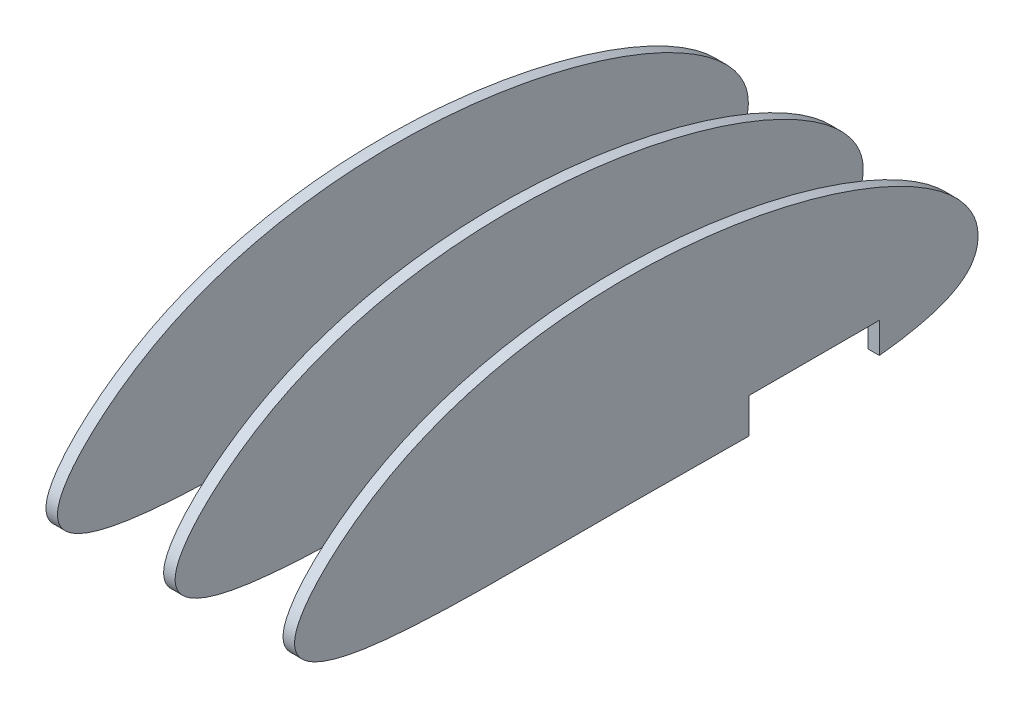
from build123d import *

# Parameters (mm, degrees)
AUFSATZ_LINEAR_AUSTRAGEN1_DEPTH = 5
AUFSATZ_LINEAR_AUSTRAGEN2_DEPTH = 5
AUFSATZ_LINEAR_AUSTRAGEN3_DEPTH = 5
SKIZZE6_W                       = 56.778057412
SKIZZE6_H                       = 23.09155445
SCHNITT_LINEAR_AUSTRAGEN2_DEPTH = 342.437715458


with BuildPart() as part:
    # Skizze3 → Aufsatz-Linear austragen1 (new body)
    with BuildSketch(Plane(origin=(50, 0, 0), x_dir=(0, 0, -1), z_dir=(1, 0, 0))):
        with BuildLine():
            add(Edge.make_bspline(
                [(-26.833255807, 32.258899596), (-29.851358797, 34.013625224), (-32.926865489, 35.630950416), (-39.164492471, 38.658284107), (-42.326908849, 40.067583895), (-48.722868649, 42.715935101), (-51.956534754, 43.954692869), (-58.48535321, 46.285036067), (-61.780563865, 47.376481945), (-66.764858936, 48.914367189), (-68.432672738, 49.410189153), (-71.77061665, 50.367007077), (-73.442119314, 50.828430966), (-78.463863987, 52.164133017), (-81.821324876, 52.989961027), (-91.92052948, 55.287427261), (-98.688922508, 56.580206268), (-112.291510392, 58.724129508), (-119.12576448, 59.5748762), (-132.859878253, 60.836051827), (-139.759745786, 61.246428093), (-150.161636826, 61.512387606), (-153.64146646, 61.542367078), (-160.576267019, 61.480505172), (-164.035748875, 61.388909929), (-174.389655741, 60.926129311), (-181.259661858, 60.367866929), (-194.927558547, 58.698853575), (-201.725542922, 57.588821232), (-211.859918134, 55.444173868), (-215.227559079, 54.648970866), (-220.261824369, 53.324424106), (-221.937044055, 52.860930623), (-225.281446325, 51.887692457), (-226.950348053, 51.377923863), (-235.232635317, 48.722323863), (-241.696023638, 46.246665465), (-251.112452733, 41.930763735), (-254.204325096, 40.390657114), (-260.284423309, 37.086372938), (-263.273472787, 35.323975967), (-267.678810808, 32.511243533), (-269.135957919, 31.544003616), (-272.011206933, 29.56007375), (-273.429877513, 28.543151982), (-276.228071979, 26.457763579), (-277.60763413, 25.389347329), (-280.324585393, 23.196985146), (-281.663119012, 22.072061011), (-284.287332877, 19.764499945), (-285.571587926, 18.583290757), (-288.075512369, 16.157268145), (-289.29533925, 14.912609817), (-291.065128113, 12.986581868), (-291.645001532, 12.33466916), (-292.781516557, 11.007964954), (-293.338839283, 10.332341733), (-294.964339533, 8.271186008), (-295.985872753, 6.855250252), (-297.37646587, 4.63594147), (-297.816125377, 3.87999717), (-298.631211972, 2.325277135), (-299.002733323, 1.534273861), (-299.647519027, -0.084947376), (-299.920544218, -0.913255921), (-300.224344916, -2.195766498), (-300.307525042, -2.629519756), (-300.429572383, -3.495880552), (-300.468930012, -3.930346053), (-300.498780863, -4.802175406), (-300.489285502, -5.239538581), (-300.414688359, -6.117563179), (-300.349464161, -6.554458099), (-300.072105521, -7.831762299), (-299.777515648, -8.649484794), (-299.172305365, -9.825718231), (-298.945748367, -10.20435367), (-298.453903828, -10.928443234), (-298.187783852, -11.275521559), (-297.619751922, -11.943156429), (-297.316351221, -12.265070398), (-296.686184308, -12.877143822), (-296.359636004, -13.16747451), (-295.351228508, -13.999063885), (-294.640880886, -14.501295454), (-293.164233593, -15.429108271), (-292.394168575, -15.856136567), (-290.053588188, -17.031389482), (-288.449835707, -17.680938488), (-285.191929248, -18.824350074), (-283.53711849, -19.316183908), (-280.193013526, -20.193334806), (-278.503520075, -20.578036414), (-275.099379243, -21.269741038), (-273.391984444, -21.575034593), (-269.976417288, -22.12454518), (-268.266860954, -22.368887635), (-263.134107502, -23.031843465), (-259.706888345, -23.381456015), (-252.845585371, -23.962913198), (-249.411456229, -24.193980233), (-242.538456971, -24.574779678), (-239.099568812, -24.724202538), (-228.777863429, -25.085990931), (-221.890104005, -25.213569656), (-208.108197071, -25.359135118), (-201.213530991, -25.375719573), (-187.424844878, -25.370801936), (-180.530447593, -25.34851284), (-166.741706347, -25.323434192), (-159.847364382, -25.321374591), (-139.164627733, -25.420967207), (-125.376142872, -25.610238241), (-104.694368878, -25.767623319), (-97.800721054, -25.798501526), (-84.014949045, -25.741469453), (-77.122808403, -25.654842286), (-66.786890118, -25.3461561), (-63.341971704, -25.213035699), (-56.453228064, -24.861566041), (-53.006260011, -24.64319065), (-46.132179133, -24.085770314), (-42.705531983, -23.747354802), (-35.883105401, -22.893200903), (-32.487086531, -22.378838002), (-27.429710278, -21.396742057), (-25.750104104, -21.03384113), (-22.407331125, -20.21360158), (-20.744109912, -19.756575513), (-18.266433369, -18.97248611), (-17.443423197, -18.694566969), (-15.804409746, -18.098476858), (-14.990014665, -17.780789742), (-12.583150783, -16.763832303), (-11.019945661, -16.000372602), (-8.770022399, -14.659115134), (-8.036400343, -14.178684584), (-6.634008753, -13.15236791), (-5.962401343, -12.604817087), (-4.69186901, -11.425231905), (-4.091700298, -10.792276622), (-2.985764252, -9.426364713), (-2.493720363, -8.708742893), (-1.64178977, -7.198301742), (-1.280349229, -6.40563295), (-0.688494026, -4.74870608), (-0.465470822, -3.906480078), (-0.148551378, -2.197652061), (-0.054259608, -1.331124712), (0.009015269, 0.425585196), (-0.023272577, 1.296547322), (-0.204882199, 3.024886421), (-0.354253647, 3.882266541), (-0.660678375, 5.15878813), (-0.776748792, 5.582960311), (-1.031925719, 6.417598837), (-1.171333474, 6.829476102), (-1.922778957, 8.863811761), (-2.696066415, 10.412025382), (-4.050533485, 12.644774982), (-4.535917718, 13.37499786), (-5.548774775, 14.787303971), (-6.077959959, 15.472443023), (-7.723437355, 17.474373853), (-8.897127639, 18.73816297), (-11.361182445, 21.158001606), (-12.652410629, 22.314216799), (-15.327113818, 24.53753381), (-16.700770872, 25.596492069), (-19.506293713, 27.629914005), (-20.938241057, 28.604259295), (-23.122695916, 30.012745467), (-23.8569658, 30.473359714), (-24.966856155, 31.151963666), (-25.338235095, 31.376110291), (-26.083722091, 31.82044201), (-26.455992934, 32.039558893), (-26.833255807, 32.258899596)],
                knots=[0, 0, 0, 0, 0.015625, 0.015625, 0.03125, 0.03125, 0.046875, 0.046875, 0.0625, 0.0625, 0.0703125, 0.0703125, 0.078125, 0.078125, 0.09375, 0.09375, 0.125, 0.125, 0.15625, 0.15625, 0.1875, 0.1875, 0.203125, 0.203125, 0.21875, 0.21875, 0.25, 0.25, 0.28125, 0.28125, 0.296875, 0.296875, 0.3046875, 0.3046875, 0.3125, 0.3125, 0.34375, 0.34375, 0.359375, 0.359375, 0.375, 0.375, 0.3828125, 0.3828125, 0.390625, 0.390625, 0.3984375, 0.3984375, 0.40625, 0.40625, 0.4140625, 0.4140625, 0.421875, 0.421875, 0.42578125, 0.42578125, 0.4296875, 0.4296875, 0.4375, 0.4375, 0.44140625, 0.44140625, 0.4453125, 0.4453125, 0.44921875, 0.44921875, 0.451171875, 0.451171875, 0.453125, 0.453125, 0.455078125, 0.455078125, 0.45703125, 0.45703125, 0.4609375, 0.4609375, 0.462890625, 0.462890625, 0.46484375, 0.46484375, 0.466796875, 0.466796875, 0.46875, 0.46875, 0.47265625, 0.47265625, 0.4765625, 0.4765625, 0.484375, 0.484375, 0.4921875, 0.4921875, 0.5, 0.5, 0.5078125, 0.5078125, 0.515625, 0.515625, 0.53125, 0.53125, 0.546875, 0.546875, 0.5625, 0.5625, 0.59375, 0.59375, 0.625, 0.625, 0.65625, 0.65625, 0.6875, 0.6875, 0.75, 0.75, 0.78125, 0.78125, 0.8125, 0.8125, 0.828125, 0.828125, 0.84375, 0.84375, 0.859375, 0.859375, 0.875, 0.875, 0.8828125, 0.8828125, 0.890625, 0.890625, 0.89453125, 0.89453125, 0.8984375, 0.8984375, 0.90625, 0.90625, 0.91015625, 0.91015625, 0.9140625, 0.9140625, 0.91796875, 0.91796875, 0.921875, 0.921875, 0.92578125, 0.92578125, 0.9296875, 0.9296875, 0.93359375, 0.93359375, 0.9375, 0.9375, 0.94140625, 0.94140625, 0.943359375, 0.943359375, 0.9453125, 0.9453125, 0.953125, 0.953125, 0.95703125, 0.95703125, 0.9609375, 0.9609375, 0.96875, 0.96875, 0.9765625, 0.9765625, 0.984375, 0.984375, 0.9921875, 0.9921875, 0.99609375, 0.99609375, 0.998046875, 0.998046875, 1, 1, 1, 1], degree=3))
        make_face()
    extrude(amount=-AUFSATZ_LINEAR_AUSTRAGEN1_DEPTH)


with BuildPart() as body_2:
    # Skizze4 → Aufsatz-Linear austragen2 (new body)
    with BuildSketch(Plane(origin=(100, 0, 0), x_dir=(0, 0, -1), z_dir=(1, 0, 0))):
        with BuildLine():
            add(Edge.make_bspline(
                [(-26.87177587, 32.151781888), (-29.878894348, 33.89463758), (-32.942730126, 35.501247503), (-39.156051981, 38.508718999), (-42.305828882, 39.908881957), (-48.675754179, 42.540162128), (-51.896023277, 43.770989389), (-58.397416699, 46.086458059), (-61.67859844, 47.170961539), (-66.641435263, 48.699072691), (-68.302338847, 49.191837828), (-71.626330072, 50.142732482), (-73.290816173, 50.601298799), (-78.291396881, 51.928720699), (-81.634596414, 52.749417716), (-91.690597857, 55.03254517), (-98.429632987, 56.31716174), (-111.972490564, 58.447253877), (-118.77637117, 59.292335225), (-132.448729883, 60.544643511), (-139.317215638, 60.951818608), (-149.671231272, 61.214948011), (-153.135782077, 61.244336604), (-160.041617155, 61.181863301), (-163.486559206, 61.090252697), (-173.796670884, 60.628333839), (-180.637246552, 60.071850847), (-194.24577759, 58.409153681), (-201.013825363, 57.303639007), (-211.102874823, 55.16829284), (-214.455336673, 54.376612838), (-219.466717773, 53.058044531), (-221.13428997, 52.596658493), (-224.463358185, 51.627890122), (-226.125194484, 51.120300624), (-234.372356883, 48.476122229), (-240.80803442, 46.011438609), (-250.183810764, 41.71568129), (-253.262311222, 40.182963943), (-259.31590015, 36.894601103), (-262.291748987, 35.140594751), (-266.677332836, 32.341030112), (-268.127925198, 31.378251095), (-270.990680253, 29.402918386), (-272.403114934, 28.390337405), (-275.188852279, 26.313706961), (-276.562193583, 25.249708319), (-279.266721702, 23.066267238), (-280.599069102, 21.945827451), (-283.210775593, 19.647440911), (-284.488821234, 18.470827665), (-286.980401076, 16.053989004), (-288.194093807, 14.813919908), (-289.954728193, 12.894746605), (-290.531557956, 12.245113876), (-291.661996785, 10.922951411), (-292.216339051, 10.249512877), (-293.83188939, 8.196221492), (-294.846829908, 6.785585914), (-296.227597938, 4.574338828), (-296.6639532, 3.821176637), (-297.472610357, 2.271758741), (-297.841152885, 1.482958642), (-298.479692253, -0.131243641), (-298.749591731, -0.956973246), (-299.048525837, -2.23553175), (-299.129881155, -2.667047922), (-299.248549161, -3.529411654), (-299.286283459, -3.961919451), (-299.313003734, -4.829927533), (-299.302001326, -5.265427106), (-299.224477293, -6.139834383), (-299.158019922, -6.57377524), (-298.877473992, -7.843616055), (-298.581482855, -8.656592992), (-297.975260569, -9.82605445), (-297.748791564, -10.2021202), (-297.257345018, -10.921650901), (-296.991617113, -11.266561251), (-296.424710408, -11.930056895), (-296.122050106, -12.249984206), (-295.493790505, -12.858182868), (-295.168316823, -13.146714227), (-294.163424111, -13.973234724), (-293.455803913, -14.472521502), (-291.985138165, -15.395031118), (-291.2183536, -15.819694115), (-288.887739609, -16.988715971), (-287.291053651, -17.635065734), (-284.047719516, -18.77302907), (-282.400423548, -19.262636391), (-279.071632018, -20.135932697), (-277.389939588, -20.519011973), (-274.001597566, -21.207876592), (-272.301546122, -21.512072555), (-268.901213148, -22.059553551), (-267.199297097, -22.303017628), (-262.089516554, -22.963628887), (-258.677681202, -23.312059862), (-251.847228599, -23.891560246), (-248.428566682, -24.121856686), (-241.586555743, -24.501338687), (-238.163188942, -24.650216561), (-227.888100157, -25.01052563), (-221.031487316, -25.137319976), (-207.311916208, -25.281100294), (-200.448435521, -25.296688194), (-186.721965382, -25.289115629), (-179.858681007, -25.265168948), (-166.132157003, -25.235571711), (-159.268918848, -25.23052382), (-138.679459182, -25.319563731), (-124.953100625, -25.50121898), (-104.364632986, -25.648898789), (-97.502116479, -25.676833631), (-83.77877218, -25.615216329), (-76.917926201, -25.526929485), (-66.629199125, -25.217654967), (-63.200053241, -25.084660906), (-56.342973153, -24.734373948), (-52.912225013, -24.517097047), (-46.06613817, -23.962810027), (-42.654004483, -23.626600993), (-35.862079762, -22.779079136), (-32.482043392, -22.269094571), (-27.450278131, -21.2968187), (-25.779484369, -20.937744993), (-22.455023582, -20.126873082), (-20.801301762, -19.675371538), (-18.338526408, -18.901709719), (-17.520592363, -18.627628718), (-15.89197631, -18.040204035), (-15.079351311, -17.726069223), (-12.66945395, -16.71678735), (-11.106403767, -15.959874312), (-9.234815923, -14.855018782), (-8.864677271, -14.62598134), (-8.133798431, -14.149765108), (-7.773198539, -13.902607533), (-6.717636848, -13.138125077), (-6.045466465, -12.595731315), (-4.777183497, -11.431988665), (-4.180865809, -10.810852693), (-3.355395471, -9.807513834), (-3.091829793, -9.461034897), (-2.590925504, -8.740850868), (-2.355540482, -8.369393113), (-1.70549773, -7.235986763), (-1.341758513, -6.449370991), (-0.895854089, -5.225036666), (-0.76384575, -4.809519407), (-0.532702452, -3.963842318), (-0.43416281, -3.535248824), (-0.190339054, -2.249397259), (-0.094309209, -1.385680471), (-0.043302541, -0.081038582), (-0.04200492, 0.355372486), (-0.070755248, 1.231249295), (-0.100877198, 1.669585852), (-0.235426891, 2.971407301), (-0.384042309, 3.827372148), (-0.68704273, 5.095123193), (-0.801416396, 5.51500198), (-1.055736119, 6.34958735), (-1.196116385, 6.765429458), (-1.95363241, 8.81745532), (-2.72984905, 10.363635748), (-4.077305995, 12.580216775), (-4.55747599, 13.301684232), (-5.572132472, 14.714161662), (-6.107829091, 15.40636158), (-7.76533378, 17.417262827), (-8.94298646, 18.680171138), (-11.406043864, 21.090756114), (-12.691805383, 22.238051216), (-15.349158976, 24.44085294), (-16.720964697, 25.496252421), (-19.535446284, 27.5307748), (-20.970748854, 28.504530498), (-23.887930285, 30.379832479), (-25.368216631, 31.280354042), (-26.87177587, 32.151781888)],
                knots=[0, 0, 0, 0, 0.015625, 0.015625, 0.03125, 0.03125, 0.046875, 0.046875, 0.0625, 0.0625, 0.0703125, 0.0703125, 0.078125, 0.078125, 0.09375, 0.09375, 0.125, 0.125, 0.15625, 0.15625, 0.1875, 0.1875, 0.203125, 0.203125, 0.21875, 0.21875, 0.25, 0.25, 0.28125, 0.28125, 0.296875, 0.296875, 0.3046875, 0.3046875, 0.3125, 0.3125, 0.34375, 0.34375, 0.359375, 0.359375, 0.375, 0.375, 0.3828125, 0.3828125, 0.390625, 0.390625, 0.3984375, 0.3984375, 0.40625, 0.40625, 0.4140625, 0.4140625, 0.421875, 0.421875, 0.42578125, 0.42578125, 0.4296875, 0.4296875, 0.4375, 0.4375, 0.44140625, 0.44140625, 0.4453125, 0.4453125, 0.44921875, 0.44921875, 0.451171875, 0.451171875, 0.453125, 0.453125, 0.455078125, 0.455078125, 0.45703125, 0.45703125, 0.4609375, 0.4609375, 0.462890625, 0.462890625, 0.46484375, 0.46484375, 0.466796875, 0.466796875, 0.46875, 0.46875, 0.47265625, 0.47265625, 0.4765625, 0.4765625, 0.484375, 0.484375, 0.4921875, 0.4921875, 0.5, 0.5, 0.5078125, 0.5078125, 0.515625, 0.515625, 0.53125, 0.53125, 0.546875, 0.546875, 0.5625, 0.5625, 0.59375, 0.59375, 0.625, 0.625, 0.65625, 0.65625, 0.6875, 0.6875, 0.75, 0.75, 0.78125, 0.78125, 0.8125, 0.8125, 0.828125, 0.828125, 0.84375, 0.84375, 0.859375, 0.859375, 0.875, 0.875, 0.8828125, 0.8828125, 0.890625, 0.890625, 0.89453125, 0.89453125, 0.8984375, 0.8984375, 0.90625, 0.90625, 0.908203125, 0.908203125, 0.91015625, 0.91015625, 0.9140625, 0.9140625, 0.91796875, 0.91796875, 0.919921875, 0.919921875, 0.921875, 0.921875, 0.92578125, 0.92578125, 0.927734375, 0.927734375, 0.9296875, 0.9296875, 0.93359375, 0.93359375, 0.935546875, 0.935546875, 0.9375, 0.9375, 0.94140625, 0.94140625, 0.943359375, 0.943359375, 0.9453125, 0.9453125, 0.953125, 0.953125, 0.95703125, 0.95703125, 0.9609375, 0.9609375, 0.96875, 0.96875, 0.9765625, 0.9765625, 0.984375, 0.984375, 0.9921875, 0.9921875, 1, 1, 1, 1], degree=3))
        make_face()
    extrude(amount=-AUFSATZ_LINEAR_AUSTRAGEN2_DEPTH)


with BuildPart() as body_3:
    # Skizze5 → Aufsatz-Linear austragen3 (new body)
    with BuildSketch(Plane(origin=(150, 0, 0), x_dir=(0, 0, -1), z_dir=(1, 0, 0))):
        with BuildLine():
            add(Edge.make_bspline(
                [(-26.934625316, 31.977008325), (-29.923584812, 33.700395877), (-32.968141055, 35.289435459), (-39.141330182, 38.2643458), (-42.270245329, 39.649534478), (-48.597212259, 42.252845105), (-51.79538152, 43.470683174), (-58.251543464, 45.761797702), (-61.509592123, 46.834938897), (-66.437050632, 48.347060221), (-68.086502181, 48.834808638), (-71.387491662, 49.776019214), (-73.040411177, 50.229914879), (-78.006105372, 51.54380688), (-81.325798743, 52.356125088), (-91.310596427, 54.615854626), (-98.001253579, 55.887176063), (-111.445694747, 57.994798683), (-118.199535186, 58.830711043), (-131.770162292, 60.068760313), (-138.586956291, 60.470846689), (-147.149591328, 60.686487338), (-148.864210029, 60.715201173), (-152.297727352, 60.743135027), (-154.015503075, 60.742320806), (-159.159134417, 60.694881836), (-162.580153517, 60.6033642), (-172.818210406, 60.143234894), (-179.610369366, 59.589949324), (-193.121248743, 57.938248749), (-199.84005916, 56.840501811), (-209.854573596, 54.721031683), (-213.182076795, 53.935351712), (-218.155833998, 52.626948258), (-219.810833708, 52.169143569), (-223.114693814, 51.20796248), (-224.764749046, 50.704129874), (-232.954327683, 48.07931227), (-239.344591921, 45.633169622), (-248.65378667, 41.371351899), (-251.710392937, 39.851066738), (-257.72062068, 36.589537624), (-260.67487992, 34.849662022), (-265.028170148, 32.072284275), (-266.467984508, 31.117073047), (-269.310398921, 29.156213119), (-270.712682616, 28.150942276), (-273.478148676, 26.08907231), (-274.841369776, 25.032524033), (-277.525702121, 22.864149907), (-278.84798029, 21.751313184), (-281.439477532, 19.468391641), (-282.707496686, 18.299544128), (-285.179171977, 15.898281584), (-286.382987964, 14.666024428), (-288.128928608, 12.758594256), (-288.700880943, 12.11288026), (-289.821606013, 10.798559156), (-290.371088256, 10.129054254), (-291.971023671, 8.089076312), (-292.975671673, 6.6874733), (-294.341333202, 4.490176295), (-294.772709305, 3.741732019), (-295.571584393, 2.201948851), (-295.935908167, 1.416844331), (-296.56558482, -0.188412725), (-296.83118198, -1.009465682), (-297.123681167, -2.280668132), (-297.202701245, -2.708570856), (-297.317171896, -3.564499692), (-297.352939275, -3.993815803), (-297.376002362, -4.85549996), (-297.363309765, -5.287867269), (-297.282692289, -6.156079494), (-297.21502695, -6.585803912), (-296.931672212, -7.844483261), (-296.634979255, -8.650212985), (-296.029652405, -9.809155644), (-295.803807976, -10.181817234), (-295.31417954, -10.894844103), (-295.049648921, -11.236636039), (-294.485660862, -11.894141363), (-294.184744512, -12.211175989), (-293.560204091, -12.814058268), (-293.236763271, -13.100099241), (-292.23839778, -13.919561119), (-291.535696126, -14.414687769), (-290.075680298, -15.329650464), (-289.314655471, -15.750934574), (-287.000525478, -16.911451372), (-285.415499596, -17.553320336), (-282.196232228, -18.683600428), (-280.561354681, -19.170028272), (-277.257897708, -20.037799041), (-275.589124745, -20.41853851), (-272.226975182, -21.103301509), (-270.538623258, -21.406021809), (-267.162928812, -21.950676365), (-265.473378546, -22.192913383), (-260.400801095, -22.85024632), (-257.013907084, -23.197021128), (-250.23350904, -23.773781412), (-246.839961576, -24.002999542), (-240.048293572, -24.380636321), (-236.650155761, -24.528749795), (-226.450868005, -24.88696818), (-219.644938814, -25.012630861), (-206.026842055, -25.153733336), (-199.214169548, -25.167779435), (-178.776288307, -25.15012201), (-165.150873414, -25.058705769), (-137.900605752, -25.154410348), (-124.275312139, -25.323662781), (-103.83867506, -25.455606977), (-97.026835363, -25.478784025), (-83.405221851, -25.409807637), (-76.595425905, -25.318889634), (-66.383843176, -25.008826612), (-62.980508303, -24.876105555), (-56.175320785, -24.527916254), (-52.773463663, -24.312697904), (-45.971873207, -23.763698057), (-42.580103658, -23.430895566), (-35.836307291, -22.594226948), (-32.482436366, -22.091468575), (-27.494635525, -21.135930279), (-25.839290132, -20.783441908), (-22.547713112, -19.988952835), (-20.911425023, -19.547216554), (-17.665122933, -18.54069892), (-16.054963998, -17.976596313), (-13.66877478, -16.994401177), (-12.878269853, -16.644095349), (-11.309709155, -15.885182627), (-10.536623452, -15.47872336), (-9.032701329, -14.60724413), (-8.299790798, -14.141365539), (-7.236045323, -13.386194363), (-6.887432674, -13.125027076), (-6.203764662, -12.581244137), (-5.869045735, -12.298749378), (-4.900210945, -11.426375455), (-4.297119239, -10.80860487), (-3.190501168, -9.488876249), (-2.68714877, -8.786771116), (-2.023161432, -7.6566335), (-1.81662075, -7.266096414), (-1.443088144, -6.477675747), (-1.274739428, -6.077686157), (-0.822320488, -4.861203491), (-0.59050477, -4.02831347), (-0.257144659, -2.321655578), (-0.155953536, -1.443792436), (-0.083409859, 0.29593511), (-0.110930664, 1.164298439), (-0.287115741, 2.898175722), (-0.437366163, 3.767336647), (-0.841989458, 5.457924553), (-1.096433611, 6.284850745), (-1.696102022, 7.906718725), (-2.04134687, 8.701653257), (-2.619343022, 9.872869946), (-2.822581429, 10.260664184), (-3.245071584, 11.024283175), (-3.464181227, 11.399992741), (-4.595526605, 13.250775512), (-5.613718139, 14.643667085), (-7.814708139, 17.301777496), (-8.999548005, 18.567987433), (-11.49233252, 20.994225754), (-12.786985899, 22.141541538), (-15.450291697, 24.33527643), (-16.819115595, 25.381461727), (-19.616765282, 27.392020569), (-21.045669008, 28.356287846), (-23.226875542, 29.751079516), (-23.960281811, 30.207369082), (-25.069200647, 30.87979189), (-25.440309723, 31.101929233), (-26.185364072, 31.542336801), (-26.561005379, 31.761584881), (-26.934625316, 31.977008325)],
                knots=[0, 0, 0, 0, 0.015625, 0.015625, 0.03125, 0.03125, 0.046875, 0.046875, 0.0625, 0.0625, 0.0703125, 0.0703125, 0.078125, 0.078125, 0.09375, 0.09375, 0.125, 0.125, 0.15625, 0.15625, 0.1875, 0.1875, 0.1953125, 0.1953125, 0.203125, 0.203125, 0.21875, 0.21875, 0.25, 0.25, 0.28125, 0.28125, 0.296875, 0.296875, 0.3046875, 0.3046875, 0.3125, 0.3125, 0.34375, 0.34375, 0.359375, 0.359375, 0.375, 0.375, 0.3828125, 0.3828125, 0.390625, 0.390625, 0.3984375, 0.3984375, 0.40625, 0.40625, 0.4140625, 0.4140625, 0.421875, 0.421875, 0.42578125, 0.42578125, 0.4296875, 0.4296875, 0.4375, 0.4375, 0.44140625, 0.44140625, 0.4453125, 0.4453125, 0.44921875, 0.44921875, 0.451171875, 0.451171875, 0.453125, 0.453125, 0.455078125, 0.455078125, 0.45703125, 0.45703125, 0.4609375, 0.4609375, 0.462890625, 0.462890625, 0.46484375, 0.46484375, 0.466796875, 0.466796875, 0.46875, 0.46875, 0.47265625, 0.47265625, 0.4765625, 0.4765625, 0.484375, 0.484375, 0.4921875, 0.4921875, 0.5, 0.5, 0.5078125, 0.5078125, 0.515625, 0.515625, 0.53125, 0.53125, 0.546875, 0.546875, 0.5625, 0.5625, 0.59375, 0.59375, 0.625, 0.625, 0.6875, 0.6875, 0.75, 0.75, 0.78125, 0.78125, 0.8125, 0.8125, 0.828125, 0.828125, 0.84375, 0.84375, 0.859375, 0.859375, 0.875, 0.875, 0.8828125, 0.8828125, 0.890625, 0.890625, 0.8984375, 0.8984375, 0.90234375, 0.90234375, 0.90625, 0.90625, 0.91015625, 0.91015625, 0.912109375, 0.912109375, 0.9140625, 0.9140625, 0.91796875, 0.91796875, 0.921875, 0.921875, 0.923828125, 0.923828125, 0.92578125, 0.92578125, 0.9296875, 0.9296875, 0.93359375, 0.93359375, 0.9375, 0.9375, 0.94140625, 0.94140625, 0.9453125, 0.9453125, 0.94921875, 0.94921875, 0.951171875, 0.951171875, 0.953125, 0.953125, 0.9609375, 0.9609375, 0.96875, 0.96875, 0.9765625, 0.9765625, 0.984375, 0.984375, 0.9921875, 0.9921875, 0.99609375, 0.99609375, 0.998046875, 0.998046875, 1, 1, 1, 1], degree=3))
        make_face()
    extrude(amount=-AUFSATZ_LINEAR_AUSTRAGEN3_DEPTH)


with BuildPart() as schnitt_linear_austragen2_tool:
    # Skizze6 → Schnitt-Linear austragen2 (new, through all)
    with BuildSketch(Plane(origin=(0, 0, 0), x_dir=(0, 0, -1), z_dir=(1, 0, 0))):
        with Locations((-71.440413227, -21.744125078)):
            Rectangle(SKIZZE6_W, SKIZZE6_H)
    extrude(amount=SCHNITT_LINEAR_AUSTRAGEN2_DEPTH)


with BuildPart() as part_1:
    add(part.part)

    # Schnitt-Linear austragen2: cut by schnitt_linear_austragen2_tool
    add(schnitt_linear_austragen2_tool.part, mode=Mode.SUBTRACT)


with BuildPart() as body_2_1:
    add(body_2.part)

    # Schnitt-Linear austragen2: cut by schnitt_linear_austragen2_tool
    add(schnitt_linear_austragen2_tool.part, mode=Mode.SUBTRACT)


with BuildPart() as body_3_1:
    add(body_3.part)

    # Schnitt-Linear austragen2: cut by schnitt_linear_austragen2_tool
    add(schnitt_linear_austragen2_tool.part, mode=Mode.SUBTRACT)


solid = Compound([part_1.part, body_2_1.part, body_3_1.part])
